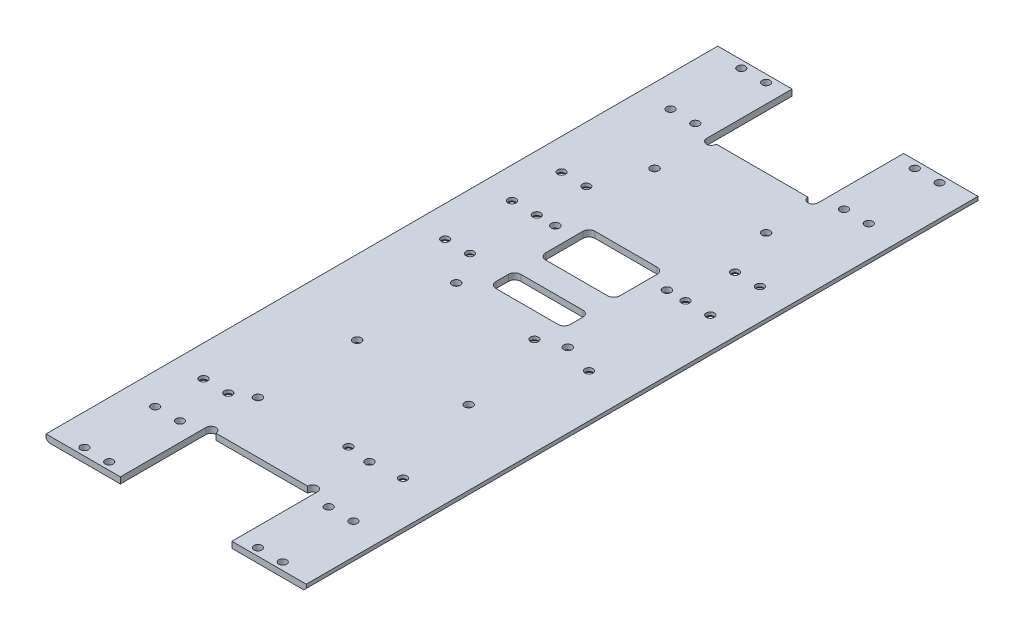
from build123d import *

# Parameters (mm, degrees)
SKETCH_1_W          = 105
SKETCH_1_H          = 271
EXTRUDE_1_DEPTH     = 2.5
SKETCH_2_R          = 1.6
CUT_EXTRUDE_1_DEPTH = 10
CHAMFER_4_SIZE      = 1
SKETCH_3_W          = 45
SKETCH_3_H          = 34.55
CUT_EXTRUDE_2_DEPTH = 10
SKETCH_4_R          = 2
CUT_EXTRUDE_3_DEPTH = 10
SKETCH_5_R          = 1.6
CUT_EXTRUDE_4_DEPTH = 10
SKETCH_6_R          = 1.6
CUT_EXTRUDE_5_DEPTH = 10
SKETCH_7_R          = 1.65
CUT_EXTRUDE_6_DEPTH = 2
CUT_EXTRUDE_7_REACH = 4.5
SKETCH_8_R          = 1.55
CHAMFER_6_SIZE      = 1.2
SKETCH_9_W          = 30
SKETCH_9_H          = 10
SKETCH_9_H_2        = 20
CUT_EXTRUDE_8_DEPTH = 12
FILLET_1_R          = 2.5


with BuildPart() as part:
    # 草图1 → 凸台-拉伸1 (new body)
    with BuildSketch(Plane(origin=(0, 0, 0), x_dir=(1, 0, 0), z_dir=(0, 1, 0))):
        Rectangle(SKETCH_1_W, SKETCH_1_H)
    extrude(amount=EXTRUDE_1_DEPTH)

    # 草图2 → 切除-拉伸1 (cut)
    with BuildSketch(Plane(origin=(0, 2.5, 0), x_dir=(1, 0, 0), z_dir=(0, 1, 0))):
        with Locations((13.000000181, -3.95)):
            Circle(SKETCH_2_R)
        with Locations((35, -3.95)):
            Circle(SKETCH_2_R)
        with Locations((35, -78.95)):
            Circle(SKETCH_2_R)
        with Locations((13.000000181, -78.95)):
            Circle(SKETCH_2_R)
    extrude(amount=-CUT_EXTRUDE_1_DEPTH, mode=Mode.SUBTRACT)

    # 倒角4
    chamfer_4_edges = [part.edges().sort_by_distance(p)[0] for p in [
        (-52.5, 0, 0),
        (52.5, 0, 0),
    ]]
    chamfer(chamfer_4_edges, length=CHAMFER_4_SIZE)

    # 草图3 → 切除-拉伸2 (cut)
    with BuildSketch(Plane.XZ):
        with Locations((0, 118.225)):
            Rectangle(SKETCH_3_W, SKETCH_3_H)
        with Locations((0, -118.225)):
            Rectangle(SKETCH_3_W, SKETCH_3_H)
    extrude(amount=-CUT_EXTRUDE_2_DEPTH, mode=Mode.SUBTRACT)

    # 草图4 → 切除-拉伸3 (cut)
    with BuildSketch(Plane.XZ):
        with Locations((20.5, -100.95)):
            Circle(SKETCH_4_R)
        with Locations((-20.5, -100.95)):
            Circle(SKETCH_4_R)
        with Locations((-20.5, 100.95)):
            Circle(SKETCH_4_R)
        with Locations((20.5, 100.95)):
            Circle(SKETCH_4_R)
    extrude(amount=-CUT_EXTRUDE_3_DEPTH, mode=Mode.SUBTRACT)

    # 草图5 → 切除-拉伸4 (cut)
    with BuildSketch(Plane(origin=(0, 2.5, 0), x_dir=(1, 0, 0), z_dir=(0, 1, 0))):
        with Locations((-40, 103.95)):
            Circle(SKETCH_5_R)
        with Locations((-30, 103.95)):
            Circle(SKETCH_5_R)
        with Locations((-40, 132.5)):
            Circle(SKETCH_5_R)
        with Locations((-30, 132.5)):
            Circle(SKETCH_5_R)
        with Locations((30, 132.5)):
            Circle(SKETCH_5_R)
        with Locations((40, 132.5)):
            Circle(SKETCH_5_R)
        with Locations((30, 103.95)):
            Circle(SKETCH_5_R)
        with Locations((40, 103.95)):
            Circle(SKETCH_5_R)
        with Locations((40, -103.95)):
            Circle(SKETCH_5_R)
        with Locations((30, -103.95)):
            Circle(SKETCH_5_R)
        with Locations((40, -132.5)):
            Circle(SKETCH_5_R)
        with Locations((30, -132.5)):
            Circle(SKETCH_5_R)
        with Locations((-30, -132.5)):
            Circle(SKETCH_5_R)
        with Locations((-40, -132.5)):
            Circle(SKETCH_5_R)
        with Locations((-30, -103.95)):
            Circle(SKETCH_5_R)
        with Locations((-40, -103.95)):
            Circle(SKETCH_5_R)
    extrude(amount=-CUT_EXTRUDE_4_DEPTH, mode=Mode.SUBTRACT)

    # 草图6 → 切除-拉伸5 (cut)
    with BuildSketch(Plane(origin=(0, 2.5, 0), x_dir=(1, 0, 0), z_dir=(0, 1, 0))):
        with Locations((40, 60)):
            Circle(SKETCH_6_R)
        with Locations((30, 60)):
            Circle(SKETCH_6_R)
        with Locations((40, 40)):
            Circle(SKETCH_6_R)
        with Locations((30, 40)):
            Circle(SKETCH_6_R)
        with Locations((-30, 40)):
            Circle(SKETCH_6_R)
        with Locations((-40, 40)):
            Circle(SKETCH_6_R)
        with Locations((-30, 60)):
            Circle(SKETCH_6_R)
        with Locations((-40, 60)):
            Circle(SKETCH_6_R)
        with Locations((-30, -84.45)):
            Circle(SKETCH_6_R)
        with Locations((-40, -84.45)):
            Circle(SKETCH_6_R)
        with Locations((-30, 13.05)):
            Circle(SKETCH_6_R)
        with Locations((-40, 13.05)):
            Circle(SKETCH_6_R)
    extrude(amount=-CUT_EXTRUDE_5_DEPTH, mode=Mode.SUBTRACT)

    # 草图7 → 切除-拉伸6 (cut)
    with BuildSketch(Plane(origin=(0, 2.5, 0), x_dir=(1, 0, 0), z_dir=(0, 1, 0))):
        with Locations((-22.5, 0)):
            Circle(SKETCH_7_R)
        with Locations((-22.5, -40)):
            Circle(SKETCH_7_R)
        with Locations((-22.5, -80)):
            Circle(SKETCH_7_R)
        with Locations((22.5, -80)):
            Circle(SKETCH_7_R)
        with Locations((22.5, -40)):
            Circle(SKETCH_7_R)
        with Locations((22.5, 0)):
            Circle(SKETCH_7_R)
        with Locations((22.5, 40)):
            Circle(SKETCH_7_R)
        with Locations((22.5, 80)):
            Circle(SKETCH_7_R)
        with Locations((-22.5, 80)):
            Circle(SKETCH_7_R)
        with Locations((-22.5, 40)):
            Circle(SKETCH_7_R)
    extrude(amount=-CUT_EXTRUDE_6_DEPTH, mode=Mode.SUBTRACT)

    # 草图8 → 切除-拉伸7 (cut, up to next)
    with BuildSketch(Plane(origin=(0, 2.5, 0), x_dir=(1, 0, 0), z_dir=(0, 1, 0)), mode=Mode.PRIVATE) as cut_extrude_7_sk1:
        with Locations((-22.5, 80)):
            Circle(SKETCH_8_R)
    cut_extrude_7_tool1 = extrude(cut_extrude_7_sk1.sketch, amount=-CUT_EXTRUDE_7_REACH, mode=Mode.PRIVATE) & part.part
    add(cut_extrude_7_tool1.solids().sort_by_distance((-22.5, 2.5, -80))[0], mode=Mode.SUBTRACT)
    # 草图8 → 切除-拉伸7 (cut, up to next)
    with BuildSketch(Plane(origin=(0, 2.5, 0), x_dir=(1, 0, 0), z_dir=(0, 1, 0)), mode=Mode.PRIVATE) as cut_extrude_7_sk2:
        with Locations((-22.5, 40)):
            Circle(SKETCH_8_R)
    cut_extrude_7_tool2 = extrude(cut_extrude_7_sk2.sketch, amount=-CUT_EXTRUDE_7_REACH, mode=Mode.PRIVATE) & part.part
    add(cut_extrude_7_tool2.solids().sort_by_distance((-22.5, 2.5, -40))[0], mode=Mode.SUBTRACT)
    # 草图8 → 切除-拉伸7 (cut, up to next)
    with BuildSketch(Plane(origin=(0, 2.5, 0), x_dir=(1, 0, 0), z_dir=(0, 1, 0)), mode=Mode.PRIVATE) as cut_extrude_7_sk3:
        with Locations((-22.5, 0)):
            Circle(SKETCH_8_R)
    cut_extrude_7_tool3 = extrude(cut_extrude_7_sk3.sketch, amount=-CUT_EXTRUDE_7_REACH, mode=Mode.PRIVATE) & part.part
    add(cut_extrude_7_tool3.solids().sort_by_distance((-22.5, 2.5, 0))[0], mode=Mode.SUBTRACT)
    # 草图8 → 切除-拉伸7 (cut, up to next)
    with BuildSketch(Plane(origin=(0, 2.5, 0), x_dir=(1, 0, 0), z_dir=(0, 1, 0)), mode=Mode.PRIVATE) as cut_extrude_7_sk4:
        with Locations((-22.5, -40)):
            Circle(SKETCH_8_R)
    cut_extrude_7_tool4 = extrude(cut_extrude_7_sk4.sketch, amount=-CUT_EXTRUDE_7_REACH, mode=Mode.PRIVATE) & part.part
    add(cut_extrude_7_tool4.solids().sort_by_distance((-22.5, 2.5, 40))[0], mode=Mode.SUBTRACT)
    # 草图8 → 切除-拉伸7 (cut, up to next)
    with BuildSketch(Plane(origin=(0, 2.5, 0), x_dir=(1, 0, 0), z_dir=(0, 1, 0)), mode=Mode.PRIVATE) as cut_extrude_7_sk5:
        with Locations((-22.5, -80)):
            Circle(SKETCH_8_R)
    cut_extrude_7_tool5 = extrude(cut_extrude_7_sk5.sketch, amount=-CUT_EXTRUDE_7_REACH, mode=Mode.PRIVATE) & part.part
    add(cut_extrude_7_tool5.solids().sort_by_distance((-22.5, 2.5, 80))[0], mode=Mode.SUBTRACT)
    # 草图8 → 切除-拉伸7 (cut, up to next)
    with BuildSketch(Plane(origin=(0, 2.5, 0), x_dir=(1, 0, 0), z_dir=(0, 1, 0)), mode=Mode.PRIVATE) as cut_extrude_7_sk6:
        with Locations((22.5, -80)):
            Circle(SKETCH_8_R)
    cut_extrude_7_tool6 = extrude(cut_extrude_7_sk6.sketch, amount=-CUT_EXTRUDE_7_REACH, mode=Mode.PRIVATE) & part.part
    add(cut_extrude_7_tool6.solids().sort_by_distance((22.5, 2.5, 80))[0], mode=Mode.SUBTRACT)
    # 草图8 → 切除-拉伸7 (cut, up to next)
    with BuildSketch(Plane(origin=(0, 2.5, 0), x_dir=(1, 0, 0), z_dir=(0, 1, 0)), mode=Mode.PRIVATE) as cut_extrude_7_sk7:
        with Locations((22.5, -40)):
            Circle(SKETCH_8_R)
    cut_extrude_7_tool7 = extrude(cut_extrude_7_sk7.sketch, amount=-CUT_EXTRUDE_7_REACH, mode=Mode.PRIVATE) & part.part
    add(cut_extrude_7_tool7.solids().sort_by_distance((22.5, 2.5, 40))[0], mode=Mode.SUBTRACT)
    # 草图8 → 切除-拉伸7 (cut, up to next)
    with BuildSketch(Plane(origin=(0, 2.5, 0), x_dir=(1, 0, 0), z_dir=(0, 1, 0)), mode=Mode.PRIVATE) as cut_extrude_7_sk8:
        with Locations((22.5, 0)):
            Circle(SKETCH_8_R)
    cut_extrude_7_tool8 = extrude(cut_extrude_7_sk8.sketch, amount=-CUT_EXTRUDE_7_REACH, mode=Mode.PRIVATE) & part.part
    add(cut_extrude_7_tool8.solids().sort_by_distance((22.5, 2.5, 0))[0], mode=Mode.SUBTRACT)
    # 草图8 → 切除-拉伸7 (cut, up to next)
    with BuildSketch(Plane(origin=(0, 2.5, 0), x_dir=(1, 0, 0), z_dir=(0, 1, 0)), mode=Mode.PRIVATE) as cut_extrude_7_sk9:
        with Locations((22.5, 40)):
            Circle(SKETCH_8_R)
    cut_extrude_7_tool9 = extrude(cut_extrude_7_sk9.sketch, amount=-CUT_EXTRUDE_7_REACH, mode=Mode.PRIVATE) & part.part
    add(cut_extrude_7_tool9.solids().sort_by_distance((22.5, 2.5, -40))[0], mode=Mode.SUBTRACT)
    # 草图8 → 切除-拉伸7 (cut, up to next)
    with BuildSketch(Plane(origin=(0, 2.5, 0), x_dir=(1, 0, 0), z_dir=(0, 1, 0)), mode=Mode.PRIVATE) as cut_extrude_7_sk10:
        with Locations((22.5, 80)):
            Circle(SKETCH_8_R)
    cut_extrude_7_tool10 = extrude(cut_extrude_7_sk10.sketch, amount=-CUT_EXTRUDE_7_REACH, mode=Mode.PRIVATE) & part.part
    add(cut_extrude_7_tool10.solids().sort_by_distance((22.5, 2.5, -80))[0], mode=Mode.SUBTRACT)

    # 倒角6
    chamfer_6_edges = [part.edges().sort_by_distance(p)[0] for p in [
        (11.400000181, 0, 3.95),
        (-41.6, 0, -40),
        (33.4, 0, 78.95),
        (-31.6, 0, -60),
        (-41.6, 0, -60),
        (-31.6, 0, 84.45),
        (28.4, 0, -60),
        (38.4, 0, -40),
        (28.4, 0, -40),
        (-31.6, 0, -40),
        (-41.6, 0, -13.05),
        (-31.6, 0, -13.05),
        (-41.6, 0, 84.45),
        (11.400000181, 0, 78.95),
        (38.4, 0, -60),
        (33.4, 0, 3.95),
    ]]
    chamfer(chamfer_6_edges, length=CHAMFER_6_SIZE)

    # 草图9 → 切除-拉伸8 (cut)
    with BuildSketch(Plane.XZ):
        with Locations((0, -11.05)):
            Rectangle(SKETCH_9_W, SKETCH_9_H)
        with Locations((0, -36.05)):
            Rectangle(SKETCH_9_W, SKETCH_9_H_2)
    extrude(amount=-CUT_EXTRUDE_8_DEPTH, mode=Mode.SUBTRACT)

    # 圆角1
    fillet_1_edges = [part.edges().sort_by_distance(p)[0] for p in [
        (15, 1.25, -6.05),
        (15, 1.25, -16.05),
        (-15, 1.25, -16.05),
        (-15, 1.25, -6.05),
        (15, 1.25, -46.05),
        (-15, 1.25, -46.05),
        (-15, 1.25, -26.05),
        (15, 1.25, -26.05),
    ]]
    fillet(fillet_1_edges, radius=FILLET_1_R)


solid = part.part
